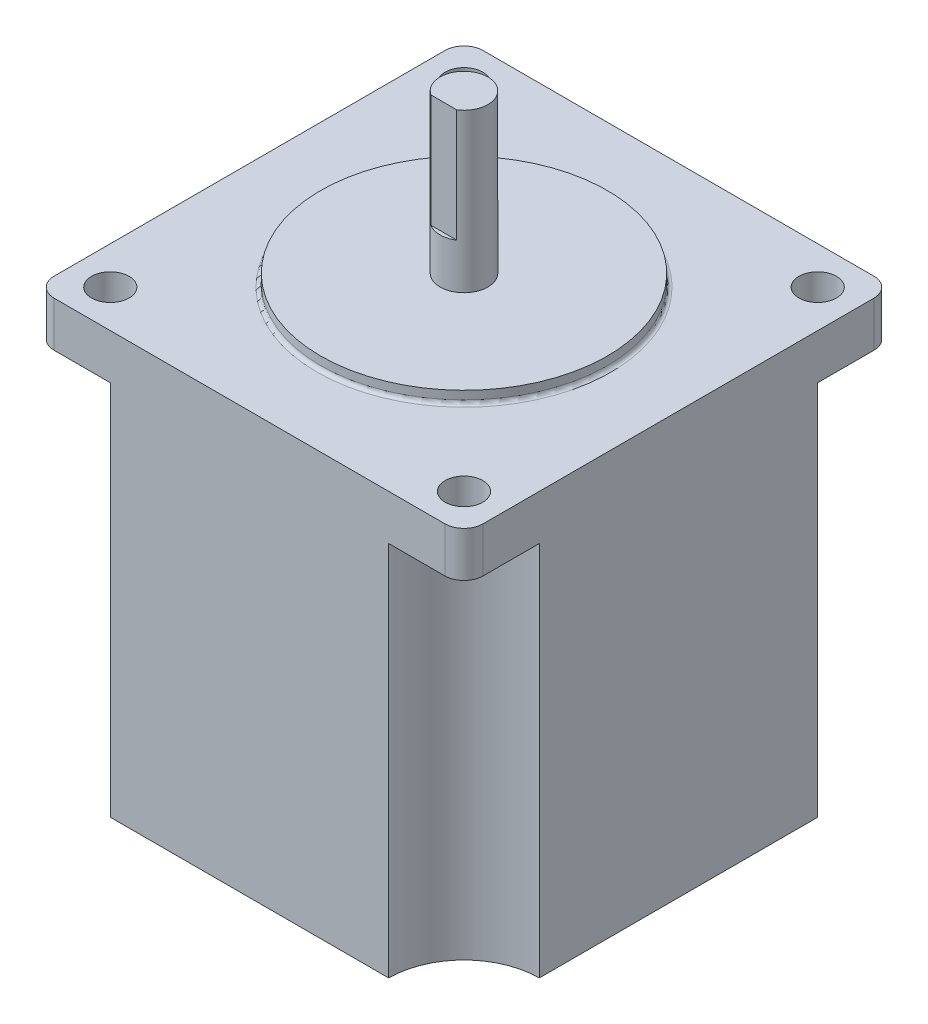
from build123d import *

# Parameters (mm, degrees)
SKETCH1_W           = 57
SKETCH1_H           = 57
BOSS_EXTRUDE2_DEPTH = 56
CUT_EXTRUDE1_DEPTH  = 50
FILLET1_R           = 2.54
SKETCH3_R           = 2.499995
CUT_EXTRUDE2_DEPTH  = 25.4
SKETCH4_R           = 19.05
BOSS_EXTRUDE3_DEPTH = 1.6
FILLET2_R           = 0.5
SKETCH5_R           = 3.175
BOSS_EXTRUDE4_DEPTH = 21
CUT_EXTRUDE4_DEPTH  = 15


with BuildPart() as part:
    # Sketch1 → Boss-Extrude2 (new body)
    with BuildSketch(Plane(origin=(0, 0, 0), x_dir=(1, 0, 0), z_dir=(0, 1, 0))):
        Rectangle(SKETCH1_W, SKETCH1_H)
    extrude(amount=BOSS_EXTRUDE2_DEPTH)

    # Sketch2 → Cut-Extrude1 (cut)
    with BuildSketch(Plane.XZ):
        with BuildLine():
            Line((28.5, -18.5), (28.5, -28.5))
            Line((28.5, -28.5), (18.5, -28.5))
            ThreePointArc((18.5, -28.5), (21.428932188, -21.428932188), (28.5, -18.5))
        make_face()
        with BuildLine():
            Line((-28.5, -28.5), (-28.5, -18.5))
            ThreePointArc((-28.5, -18.5), (-21.428932188, -21.428932188), (-18.5, -28.5))
            Line((-18.5, -28.5), (-28.5, -28.5))
        make_face()
        with BuildLine():
            Line((-28.5, 28.5), (-18.5, 28.5))
            ThreePointArc((-18.5, 28.5), (-21.428932188, 21.428932188), (-28.5, 18.5))
            Line((-28.5, 18.5), (-28.5, 28.5))
        make_face()
        with BuildLine():
            Line((28.5, 28.5), (28.5, 18.5))
            ThreePointArc((28.5, 18.5), (21.428932188, 21.428932188), (18.5, 28.5))
            Line((18.5, 28.5), (28.5, 28.5))
        make_face()
    extrude(amount=-CUT_EXTRUDE1_DEPTH, mode=Mode.SUBTRACT)

    # Fillet1
    fillet1_edges = [part.edges().sort_by_distance(p)[0] for p in [
        (-28.5, 53, -28.5),
        (28.5, 53, -28.5),
        (28.5, 53, 28.5),
        (-28.5, 53, 28.5),
    ]]
    fillet(fillet1_edges, radius=FILLET1_R)

    # Sketch3 → Cut-Extrude2 (cut)
    with BuildSketch(Plane(origin=(0, 56, 0), x_dir=(1, 0, 0), z_dir=(0, 1, 0))):
        with Locations((-23.50001, -23.50001)):
            Circle(SKETCH3_R)
        with Locations((-23.50001, 23.50001)):
            Circle(SKETCH3_R)
        with Locations((23.50001, 23.50001)):
            Circle(SKETCH3_R)
        with Locations((23.50001, -23.50001)):
            Circle(SKETCH3_R)
    extrude(amount=-CUT_EXTRUDE2_DEPTH, mode=Mode.SUBTRACT)

    # Sketch4 → Boss-Extrude3 (add)
    with BuildSketch(Plane(origin=(0, 56, 0), x_dir=(1, 0, 0), z_dir=(0, 1, 0))):
        Circle(SKETCH4_R)
    extrude(amount=BOSS_EXTRUDE3_DEPTH)

    # Fillet2
    fillet2_edges = [part.edges().sort_by_distance(p)[0] for p in [
        (-19.05, 56, 0),
    ]]
    fillet(fillet2_edges, radius=FILLET2_R)

    # Sketch5 → Boss-Extrude4 (add)
    with BuildSketch(Plane(origin=(0, 57.6, 0), x_dir=(1, 0, 0), z_dir=(0, 1, 0))):
        Circle(SKETCH5_R)
    extrude(amount=BOSS_EXTRUDE4_DEPTH)

    # Sketch6 → Cut-Extrude4 (cut)
    with BuildSketch(Plane(origin=(0, 78.6, 0), x_dir=(1, 0, 0), z_dir=(0, 1, 0))):
        with BuildLine():
            Line((1.710263138, -2.675), (-1.710263138, -2.675))
            ThreePointArc((-1.710263138, -2.675), (0, -3.175), (1.710263138, -2.675))
        make_face()
    extrude(amount=-CUT_EXTRUDE4_DEPTH, mode=Mode.SUBTRACT)


solid = part.part
